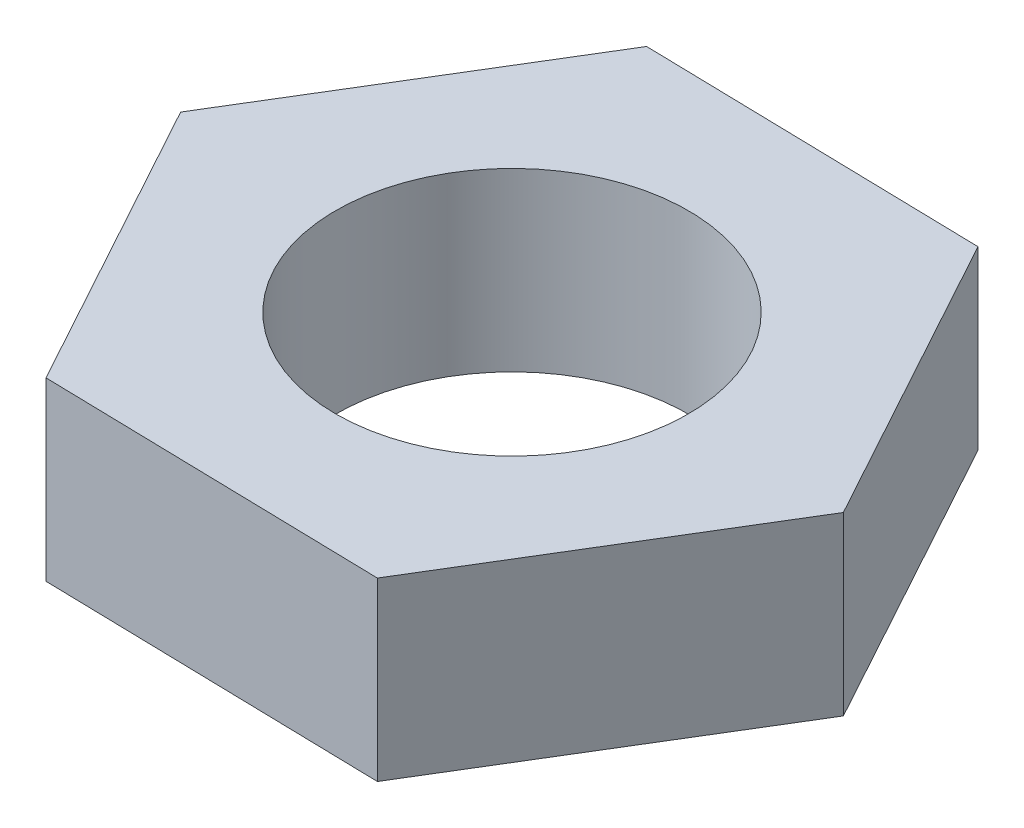
from build123d import *

# Parameters (mm, degrees)
BOSS_EXTRU_1_DEPTH      = 10
ESQUISSE2_R             = 10
ENL_V_MAT_EXTRU_1_DEPTH = 10


with BuildPart() as part:
    # Esquisse1 → Boss.-Extru.1 (new body)
    with BuildSketch(Plane(origin=(0, 0, 0), x_dir=(1, 0, 0), z_dir=(0, 1, 0))):
        Polygon((-19.241998651, 0.437632283), (-10, -16.44524351), (9.241998651, -16.882875793), (19.241998651, -0.437632283), (10, 16.44524351), (-9.241998651, 16.882875793), align=None)
    extrude(amount=BOSS_EXTRU_1_DEPTH)

    # Esquisse2 → Enlèv. mat.-Extru.1 (cut)
    with BuildSketch(Plane(origin=(0, 10, 0), x_dir=(1, 0, 0), z_dir=(0, 1, 0))):
        Circle(ESQUISSE2_R)
    extrude(amount=-ENL_V_MAT_EXTRU_1_DEPTH, mode=Mode.SUBTRACT)


solid = part.part
